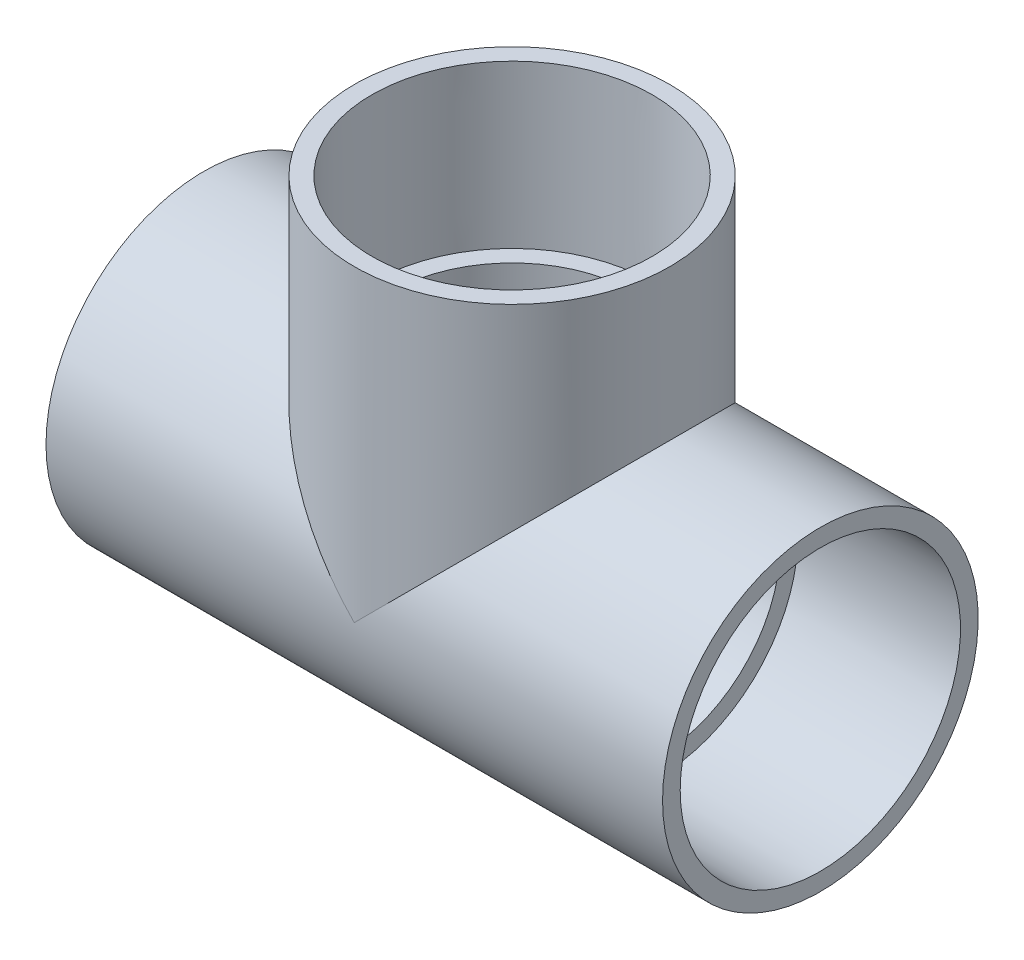
from build123d import *

# Parameters (mm, degrees)
BOSS_EXTRUDE1_DEPTH = 63.5
BOSS_EXTRUDE2_REACH = 67.881
SKETCH5_R           = 26.2509
CUT_EXTRUDE1_DEPTH  = 63.5
CUT_EXTRUDE2_START  = -31.75
SKETCH6_R           = 26.2509
CUT_EXTRUDE2_DEPTH  = 31.75


with BuildPart() as part:
    # Sketch1 → Revolve1 (revolve)
    with BuildSketch(Plane.XY):
        Polygon((-66.675, -34.13125), (-31.75, -34.13125), (-31.75, -30.0863), (-66.675, -30.3149), align=None)
    revolve(axis=Axis((-66.675, 0, 0), (1, 0, 0)))


with BuildPart() as body_2:
    # Mirror1: mirrored copy
    add(part.part.mirror(Plane(origin=(0, 0, 0), x_dir=(0, 0, 1), z_dir=(1, 0, 0))))


with BuildPart() as body_3:
    # Sketch2 → Revolve2 (revolve)
    with BuildSketch(Plane.XY):
        Polygon((30.3149, 66.675), (30.0863, 31.75), (34.13125, 31.75), (34.13125, 66.675), align=None)
    revolve(axis=Axis((0, 0, 0), (0, 1, 0)))


with BuildPart() as part_1:
    add(part.part)

    add(body_2.part)  # Boss-Extrude1 merges body 2

    add(body_3.part)  # Boss-Extrude1 merges body 3
    # Sketch3 → Boss-Extrude1 (add)
    with BuildSketch(Plane(origin=(-31.75, 0, 0), x_dir=(0, 0, -1), z_dir=(1, 0, 0))):
        with BuildLine():
            Line((12.525163734, 31.75), (-12.525163734, 31.75))
            ThreePointArc((-12.525163734, 31.75), (0, -34.13125), (12.525163734, 31.75))
        make_face()
    extrude(amount=BOSS_EXTRUDE1_DEPTH)

    # Sketch4 → Boss-Extrude2 (add, up to next)
    with BuildSketch(Plane.XZ.offset(-31.75), mode=Mode.PRIVATE) as boss_extrude2_sk1:
        with BuildLine():
            ThreePointArc((-31.75, -12.525163734), (0, -34.13125), (31.75, -12.525163734))
            Line((31.75, -12.525163734), (-31.75, -12.525163734))
        make_face()
    boss_extrude2_tool1 = extrude(boss_extrude2_sk1.sketch, amount=BOSS_EXTRUDE2_REACH, mode=Mode.PRIVATE) - part_1.part
    add(boss_extrude2_tool1.solids().sort_by_distance((0, 31.75, -21.455636))[0])
    # Sketch4 → Boss-Extrude2 (add, up to next)
    with BuildSketch(Plane.XZ.offset(-31.75), mode=Mode.PRIVATE) as boss_extrude2_sk2:
        with BuildLine():
            ThreePointArc((31.75, 12.525163734), (0, 34.13125), (-31.75, 12.525163734))
            Line((-31.75, 12.525163734), (31.75, 12.525163734))
        make_face()
    boss_extrude2_tool2 = extrude(boss_extrude2_sk2.sketch, amount=BOSS_EXTRUDE2_REACH, mode=Mode.PRIVATE) - part_1.part
    add(boss_extrude2_tool2.solids().sort_by_distance((0, 31.75, 21.455636))[0])

    # Sketch5 → Cut-Extrude1 (cut)
    with BuildSketch(Plane.ZY.offset(31.75)):
        Circle(SKETCH5_R)
    extrude(amount=-CUT_EXTRUDE1_DEPTH, mode=Mode.SUBTRACT)

    # Sketch6 → Cut-Extrude2 (cut)
    with BuildSketch(Plane(origin=(0, 31.75, 0), x_dir=(1, 0, 0), z_dir=(0, 1, 0)).offset(CUT_EXTRUDE2_START)):
        Circle(SKETCH6_R)
    extrude(amount=CUT_EXTRUDE2_DEPTH, mode=Mode.SUBTRACT)


solid = part_1.part
